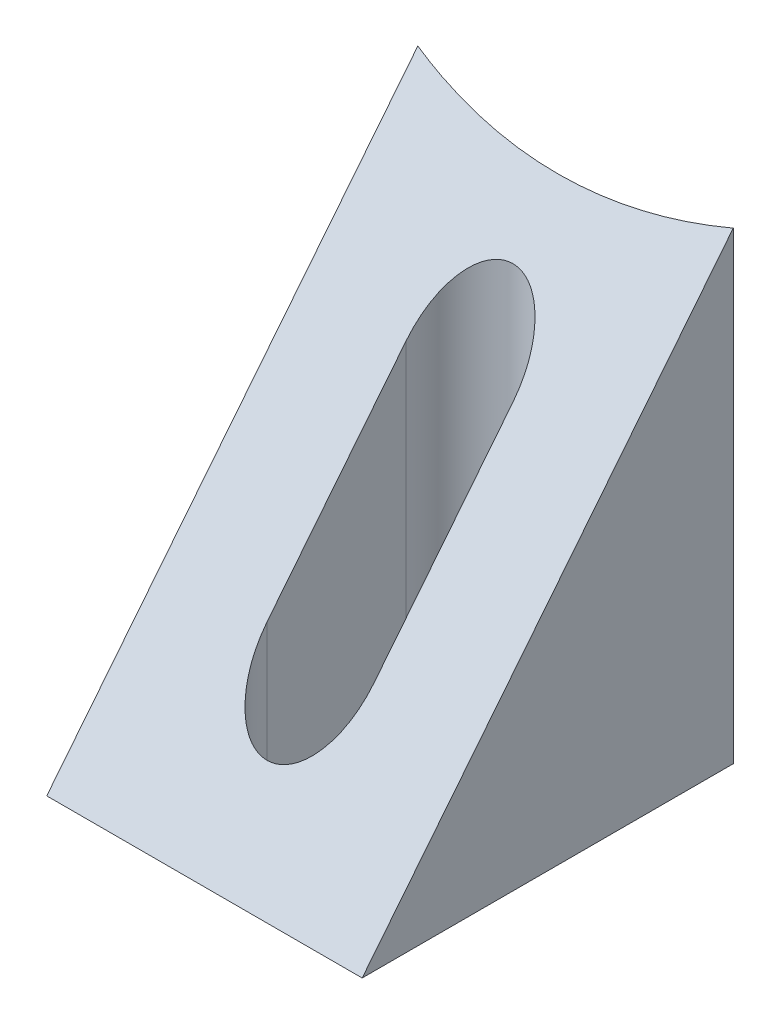
from build123d import *

# Parameters (mm, degrees)
SKETCH1_W      = 6.8
SKETCH1_H      = 8
EXTRUDE1_DEPTH = 10
EXTRUDE2_DEPTH = 7.8
EXTRUDE3_DEPTH = 11
SKETCH4_R      = 15.011245784
EXTRUDE4_DEPTH = 11


with BuildPart() as part:
    # Sketch1 → Extrude1 (new body)
    with BuildSketch(Plane(origin=(0, 0, 0), x_dir=(1, 0, 0), z_dir=(0, 1, 0))):
        Rectangle(SKETCH1_W, SKETCH1_H)
    extrude(amount=EXTRUDE1_DEPTH)

    # Sketch2 → Extrude2 (cut, through all)
    with BuildSketch(Plane(origin=(3.4, 0, 0), x_dir=(0, 0, -1), z_dir=(1, 0, 0))):
        Polygon((4, 10), (-4, 0), (-4, 10), align=None)
    extrude(amount=-EXTRUDE2_DEPTH, mode=Mode.SUBTRACT)

    # Sketch3 → Extrude3 (cut, through all)
    with BuildSketch(Plane.XZ):
        with BuildLine():
            Line((1.15, 1.5), (1.15, -1.5))
            ThreePointArc((1.15, -1.5), (0, -2.65), (-1.15, -1.5))
            Line((-1.15, -1.5), (-1.15, 1.5))
            ThreePointArc((-1.15, 1.5), (0, 2.65), (1.15, 1.5))
        make_face()
    extrude(amount=-EXTRUDE3_DEPTH, mode=Mode.SUBTRACT)

    # Sketch4 → Extrude4 (cut, through all)
    with BuildSketch(Plane.XZ):
        with Locations((0, -18.621131967)):
            Circle(SKETCH4_R)
    extrude(amount=-EXTRUDE4_DEPTH, mode=Mode.SUBTRACT)


solid = part.part
